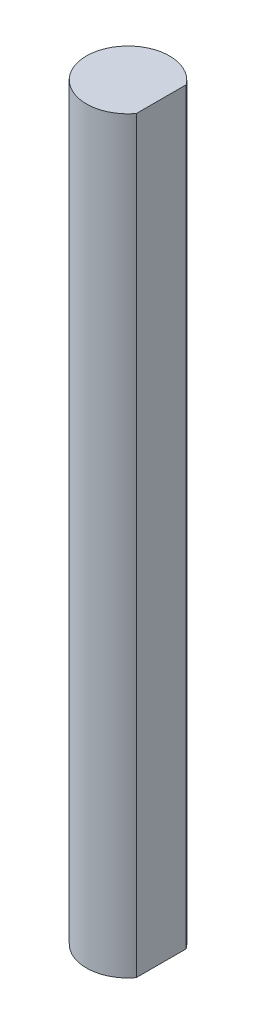
from build123d import *

# Parameters (mm, degrees)
BOSS_EXTRUDE1_DEPTH = 57.15


with BuildPart() as part:
    # Sketch1 → Boss-Extrude1 (new body)
    with BuildSketch(Plane(origin=(0, 0, 0), x_dir=(1, 0, 0), z_dir=(0, 1, 0))):
        with BuildLine():
            Line((2.54, -1.905), (2.54, 1.905))
            ThreePointArc((2.54, 1.905), (-3.175, 0), (2.54, -1.905))
        make_face()
    extrude(amount=BOSS_EXTRUDE1_DEPTH)


solid = part.part
